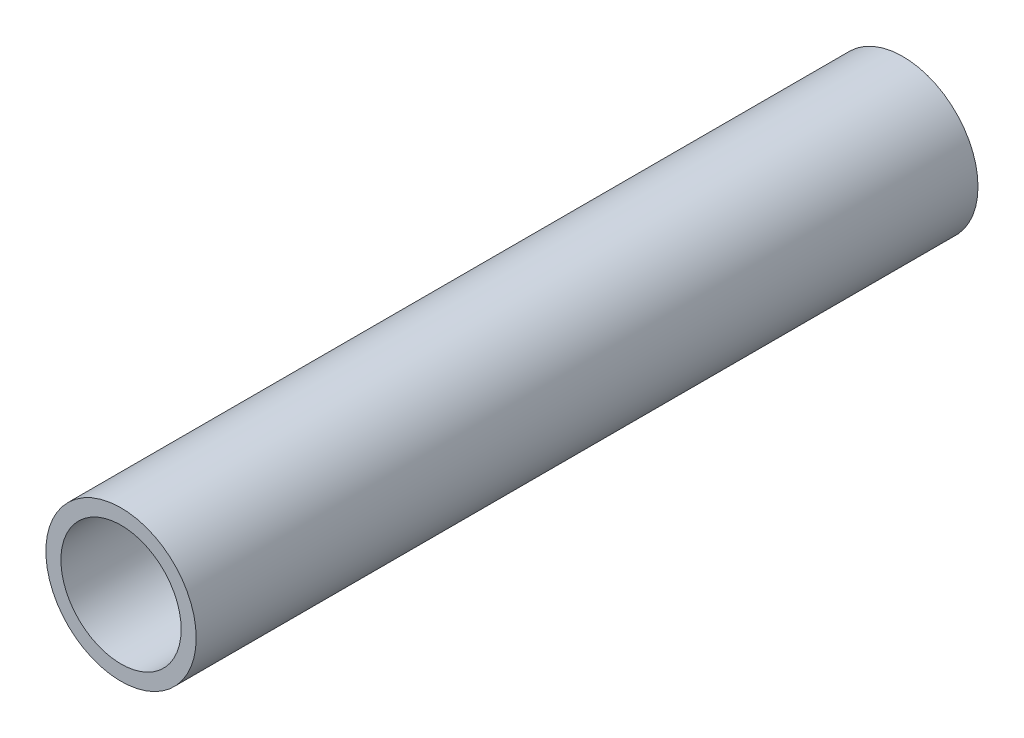
from build123d import *

# Parameters (mm, degrees)
CROQUIS1_R              = 12.5
CROQUIS1_R_2            = 10
SALIENTE_EXTRUIR1_DEPTH = 130


with BuildPart() as part:
    # Croquis1 → Saliente-Extruir1 (new body)
    with BuildSketch(Plane.XY):
        Circle(CROQUIS1_R)
        Circle(CROQUIS1_R_2, mode=Mode.SUBTRACT)
    extrude(amount=SALIENTE_EXTRUIR1_DEPTH)


solid = part.part
